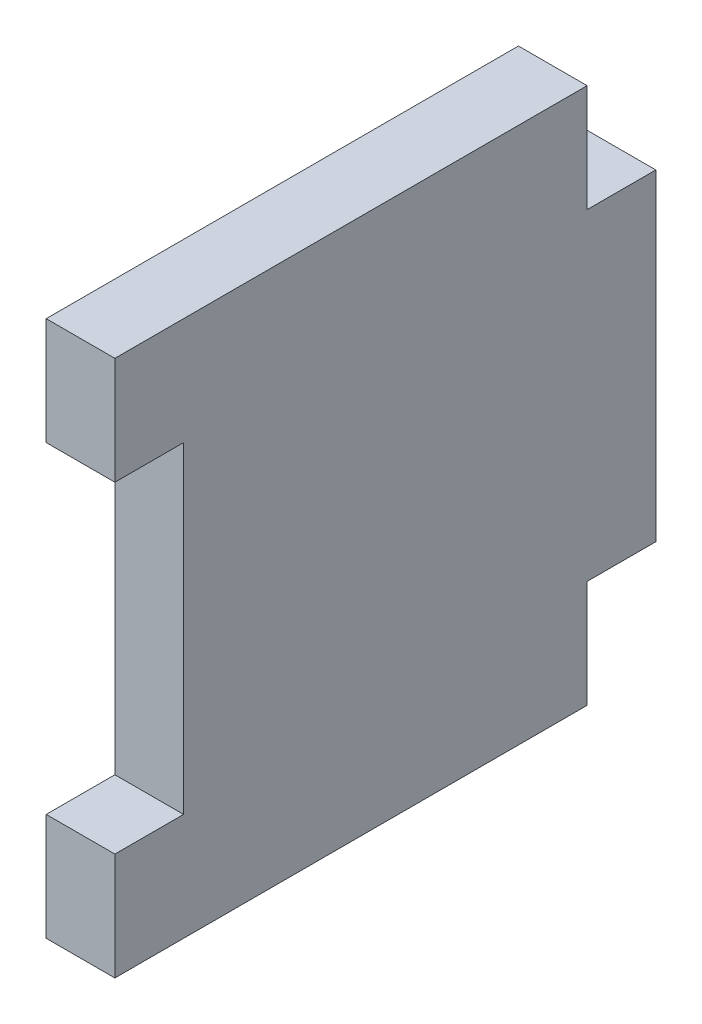
from build123d import *

# Parameters (mm, degrees)
BOSS_EXTRUDE1_DEPTH = 3.2


with BuildPart() as part:
    # Sketch1 → Boss-Extrude1 (new body)
    with BuildSketch(Plane(origin=(0, 0, 0), x_dir=(0, 0, -1), z_dir=(1, 0, 0))):
        Polygon((0, 0), (0, 15), (-3.2, 15), (-3.2, 20), (-25.2, 20), (-25.2, 15), (-22, 15), (-22, 0), (-25.2, 0), (-25.2, -5), (-3.2, -5), (-3.2, 0), align=None)
    extrude(amount=BOSS_EXTRUDE1_DEPTH)


solid = part.part
